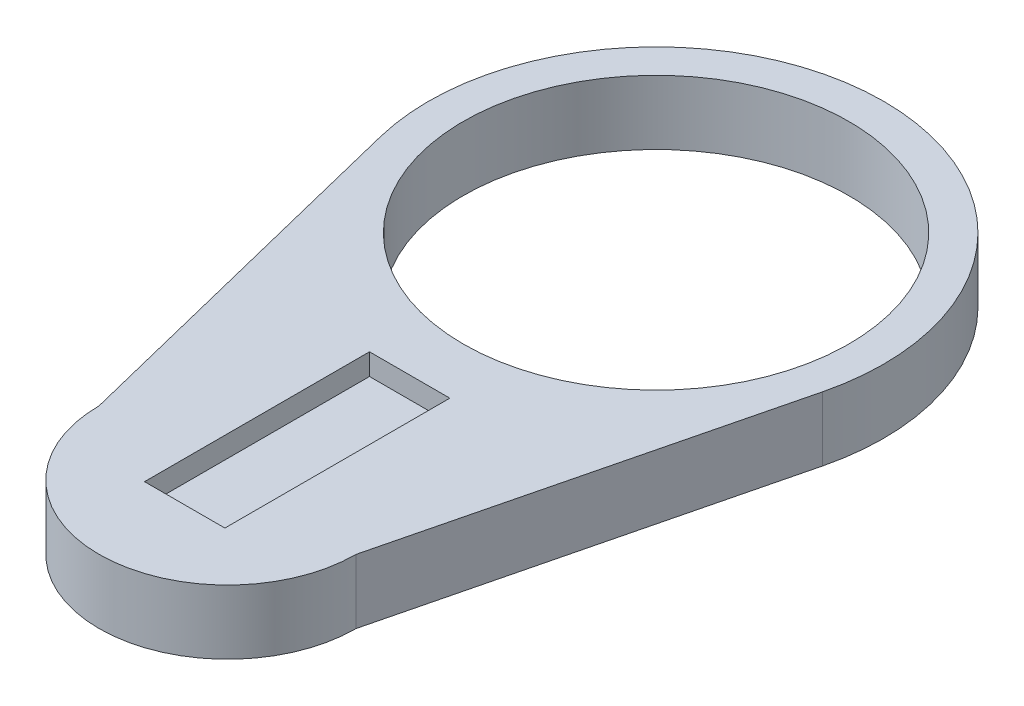
from build123d import *

# Parameters (mm, degrees)
SKETCH1_R           = 18
BOSS_EXTRUDE1_DEPTH = 6
SKETCH2_W           = 7.5
SKETCH2_H           = 21
CUT_EXTRUDE1_DEPTH  = 2


with BuildPart() as part:
    # Sketch1 → Boss-Extrude1 (new body)
    with BuildSketch(Plane(origin=(0, 0, 0), x_dir=(1, 0, 0), z_dir=(0, 1, 0))):
        with BuildLine():
            Line((-20.628820967, 34.89958379), (-12, 0))
            ThreePointArc((-12, 0), (0, -12), (12, 0))
            Line((12, 0), (20.628820967, 34.89958379))
            ThreePointArc((20.628820967, 34.89958379), (0, 61.25), (-20.628820967, 34.89958379))
        make_face()
        with Locations((0, 40)):
            Circle(SKETCH1_R, mode=Mode.SUBTRACT)
    extrude(amount=BOSS_EXTRUDE1_DEPTH)

    # Sketch2 → Cut-Extrude1 (cut)
    with BuildSketch(Plane(origin=(0, 6, 0), x_dir=(1, 0, 0), z_dir=(0, 1, 0))):
        with Locations((0, 6.5)):
            Rectangle(SKETCH2_W, SKETCH2_H)
    extrude(amount=-CUT_EXTRUDE1_DEPTH, mode=Mode.SUBTRACT)


solid = part.part
